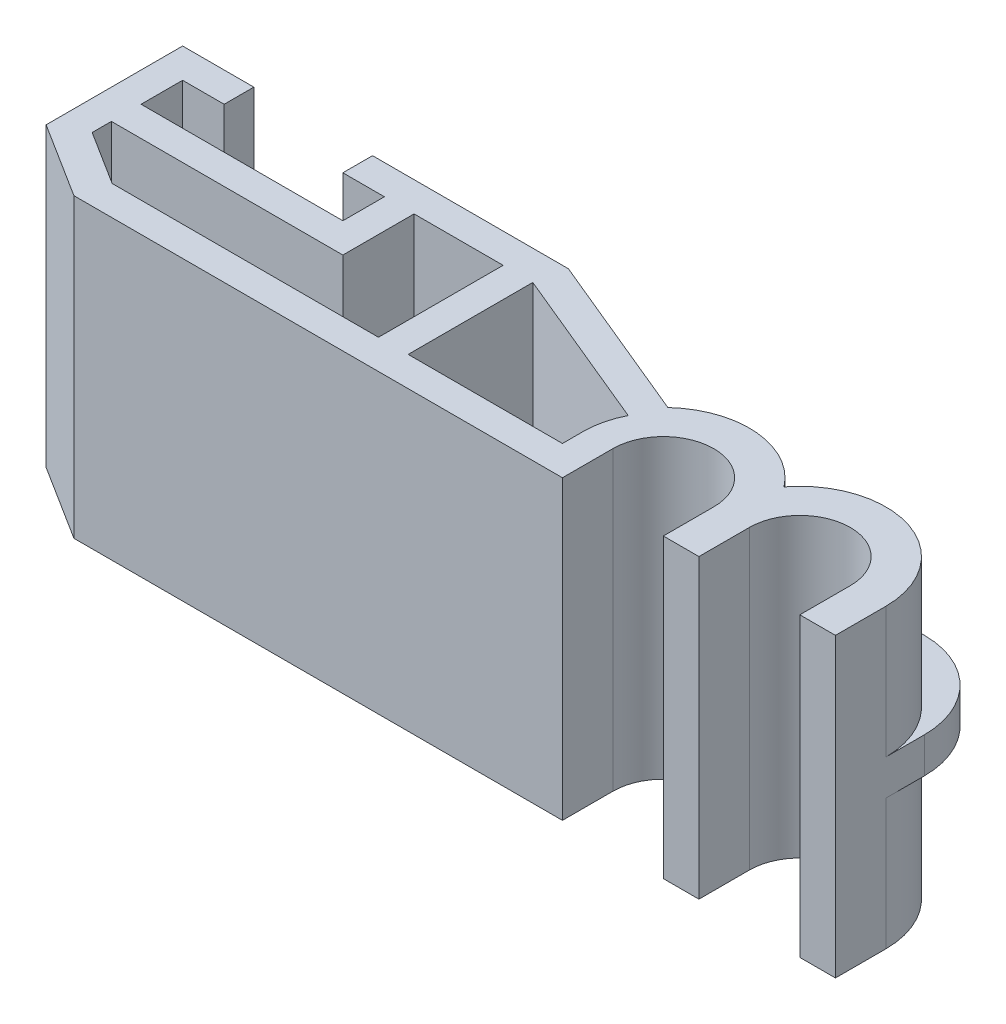
from build123d import *

# Parameters (mm, degrees)
BOSS_EXTRUDE1_DEPTH = 10
BOSS_EXTRUDE2_DEPTH = 10
CUT_EXTRUDE1_DEPTH  = 10
SHELL2_T            = -1
SKETCH4_W           = 1
SKETCH4_H           = 4.2
BOSS_EXTRUDE3_DEPTH = 9
SKETCH7_W           = 6.8
SKETCH7_H           = 1
BOSS_EXTRUDE4_DEPTH = 9
SKETCH8_W           = 4
SKETCH8_H           = 1
CUT_EXTRUDE2_DEPTH  = 8.8
BOSS_EXTRUDE5_DEPTH = 0.6


with BuildPart() as part:
    # Sketch1 → Boss-Extrude1 (new body)
    with BuildSketch(Plane(origin=(0, 0, 0), x_dir=(1, 0, 0), z_dir=(0, 1, 0))):
        with BuildLine():
            ThreePointArc((-2.9, 0), (-0.932737905, 2.745906044), (2.3, 1.766352173))
            ThreePointArc((2.3, 1.766352173), (5.532737905, 2.745906044), (7.5, 0))
            Line((7.5, 0), (7.5, -1.7))
            Line((7.5, -1.7), (6.3, -1.7))
            Line((6.3, -1.7), (6.3, 0))
            ThreePointArc((6.3, 0), (4.6, 1.7), (2.9, 0))
            Line((2.9, 0), (2.9, -1.7))
            Line((2.9, -1.7), (1.7, -1.7))
            Line((1.7, -1.7), (1.7, 0))
            ThreePointArc((1.7, 0), (0, 1.7), (-1.7, 0))
            Line((-1.7, 0), (-1.7, -1.7))
            Line((-1.7, -1.7), (-2.9, -1.7))
            Line((-2.9, -1.7), (-2.9, 0))
        make_face()
    extrude(amount=BOSS_EXTRUDE1_DEPTH)

    # Sketch2 → Boss-Extrude2 (add)
    with BuildSketch(Plane.XZ):
        with BuildLine():
            Line((-2.9, 1.7), (-20.7, 1.7))
            Line((-20.7, 1.7), (-20.7, -4.5))
            Line((-20.7, -4.5), (-7.7, -4.5))
            Line((-7.7, -4.5), (-1.972618929, -2.125740944))
            ThreePointArc((-1.972618929, -2.125740944), (-2.658062724, -1.159613105), (-2.9, 0))
            Line((-2.9, 0), (-2.9, 1.7))
        make_face()
    extrude(amount=-BOSS_EXTRUDE2_DEPTH)

    # Sketch3 → Cut-Extrude1 (cut)
    with BuildSketch(Plane.XZ):
        Polygon((-18.162284492, 1.7), (-20.7, 0.1), (-20.7, 1.7), align=None)
    extrude(amount=-CUT_EXTRUDE1_DEPTH, mode=Mode.SUBTRACT)

    # Shell2
    shell2_openings = [part.faces().sort_by_distance(p)[0] for p in [
        (-2.051423917, 10, -0.549910722),
    ]]
    offset(amount=SHELL2_T, openings=shell2_openings, kind=Kind.INTERSECTION)

    # Sketch4 → Boss-Extrude3 (add)
    with BuildSketch(Plane(origin=(0, 1, 0), x_dir=(1, 0, 0), z_dir=(0, 1, 0))):
        with Locations((-8.399059546, 1.4)):
            Rectangle(SKETCH4_W, SKETCH4_H)
    extrude(amount=BOSS_EXTRUDE3_DEPTH)

    # Sketch7 → Boss-Extrude4 (add)
    with BuildSketch(Plane(origin=(0, 1, 0), x_dir=(1, 0, 0), z_dir=(0, 1, 0))):
        with Locations((-16.3, 1.6)):
            Rectangle(SKETCH7_W, SKETCH7_H)
        Polygon((-11.9, 3.5), (-12.9, 3.5), (-12.9, 2.1), (-12.9, 1.1), (-11.9, 1.1), align=None)
    extrude(amount=BOSS_EXTRUDE4_DEPTH)

    # Sketch8 → Cut-Extrude2 (cut)
    with BuildSketch(Plane(origin=(0, 10, 0), x_dir=(1, 0, 0), z_dir=(0, 1, 0))):
        with Locations((-16.3, 4)):
            Rectangle(SKETCH8_W, SKETCH8_H)
    extrude(amount=-CUT_EXTRUDE2_DEPTH, mode=Mode.SUBTRACT)

    # Sketch9 → Boss-Extrude5 (add, symmetric)
    with BuildSketch(Plane(origin=(0, 5, 0), x_dir=(1, 0, 0), z_dir=(0, 1, 0))):
        with BuildLine():
            Line((0, 4.2), (-6.976315566, 4.2))
            Line((-6.976315566, 4.2), (-1.972618929, 2.125740944))
            ThreePointArc((-1.972618929, 2.125740944), (0.243073371, 2.889795034), (2.3, 1.766352173))
            ThreePointArc((2.3, 1.766352173), (5.532737905, 2.745906044), (7.5, 0))
            Line((7.5, 0), (7.5, 1.299833538))
            ThreePointArc((7.5, 1.299833538), (6.65066852, 3.350550812), (4.6, 4.2))
            Line((4.6, 4.2), (0, 4.2))
        make_face()
    extrude(amount=BOSS_EXTRUDE5_DEPTH, both=True)


solid = part.part
